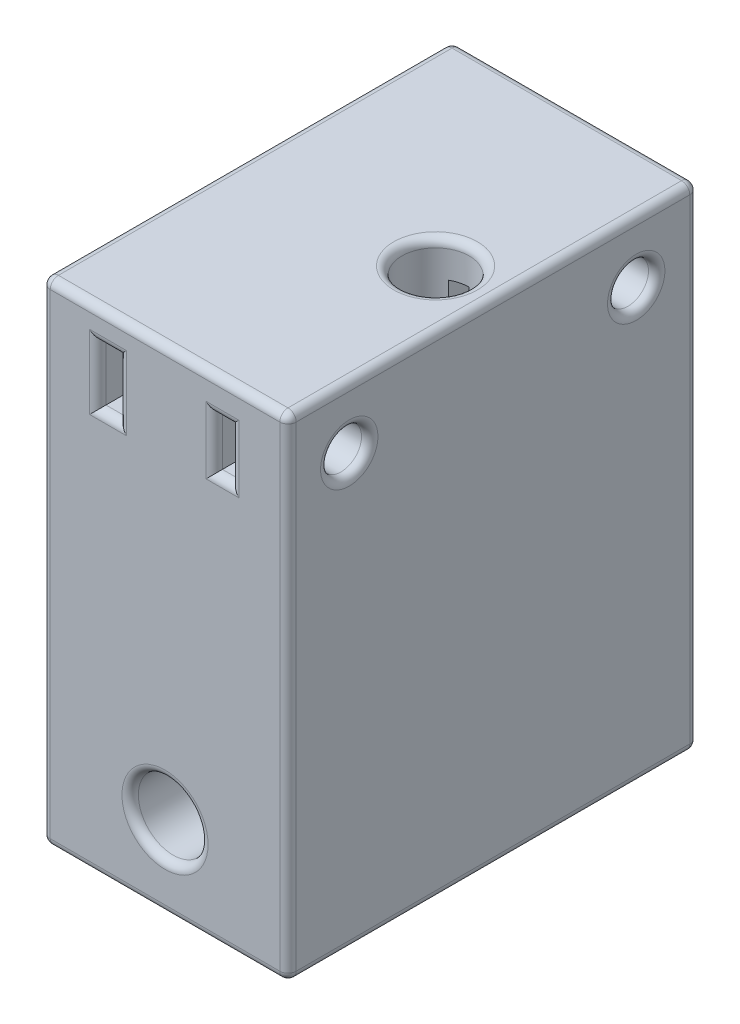
from build123d import *

# Parameters (mm, degrees)
SKETCH_1_W          = 30
SKETCH_1_H          = 60
SKETCH_1_R          = 4.25
EXTRUDE_1_DEPTH     = 50
SKETCH_2_W          = 2.5
SKETCH_2_H          = 7
SKETCH_2_W_2        = 2
SKETCH_2_H_2        = 6.2
CUT_EXTRUDE_1_DEPTH = 50
SKETCH_4_R          = 2.5
CUT_EXTRUDE_2_DEPTH = 7
FILLET_1_R          = 1
FILLET_2_R          = 1
FILLET_3_R          = 1
FILLET_4_R          = 1
FILLET_5_R          = 1
FILLET_6_R          = 1
SKETCH_5_R          = 4.1
CUT_EXTRUDE_3_DEPTH = 21
FILLET_7_R          = 1
FILLET_8_R          = 1


with BuildPart() as part:
    # 草图1 → 凸台-拉伸1 (new body)
    with BuildSketch(Plane.XY):
        with Locations((6.369509044, 21.447028424)):
            Rectangle(SKETCH_1_W, SKETCH_1_H)
        with Locations((6.369509044, 1.447028424)):
            Circle(SKETCH_1_R, mode=Mode.SUBTRACT)
    extrude(amount=EXTRUDE_1_DEPTH)

    # 草图2 → 切除-拉伸1 (cut)
    with BuildSketch(Plane.XY.offset(50)):
        with Locations((-0.580490956, 44.147028424)):
            Rectangle(SKETCH_2_W, SKETCH_2_H)
        with Locations((13.369509044, 44.047028424)):
            Rectangle(SKETCH_2_W_2, SKETCH_2_H_2)
    extrude(amount=-CUT_EXTRUDE_1_DEPTH, mode=Mode.SUBTRACT)

    # 草图4 → 切除-拉伸2 (cut)
    with BuildSketch(Plane(origin=(21.369509044, 0, 0), x_dir=(0, 0, -1), z_dir=(1, 0, 0))):
        with Locations((-42.532463012, 43.947028424)):
            Circle(SKETCH_4_R)
        with Locations((-7.532463012, 43.947028424)):
            Circle(SKETCH_4_R)
    extrude(amount=-CUT_EXTRUDE_2_DEPTH, mode=Mode.SUBTRACT)

    # 圆角1
    fillet_1_edges = [part.edges().sort_by_distance(p)[0] for p in [
        (12.369509044, 44.047028424, 50),
        (13.369509044, 40.947028424, 50),
        (14.369509044, 44.047028424, 50),
        (13.369509044, 47.147028424, 50),
    ]]
    fillet(fillet_1_edges, radius=FILLET_1_R)

    # 圆角2
    fillet_2_edges = [part.edges().sort_by_distance(p)[0] for p in [
        (-1.830490956, 44.147028424, 50),
        (-0.580490956, 40.647028424, 50),
        (0.669509044, 44.147028424, 50),
        (-0.580490956, 47.647028424, 50),
    ]]
    fillet(fillet_2_edges, radius=FILLET_2_R)

    # 圆角3
    fillet_3_edges = [part.edges().sort_by_distance(p)[0] for p in [
        (2.119509044, 1.447028424, 50),
    ]]
    fillet(fillet_3_edges, radius=FILLET_3_R)

    # 圆角4
    fillet_4_edges = [part.edges().sort_by_distance(p)[0] for p in [
        (21.369509044, 43.947028424, 45.032463012),
    ]]
    fillet(fillet_4_edges, radius=FILLET_4_R)

    # 圆角5
    fillet_5_edges = [part.edges().sort_by_distance(p)[0] for p in [
        (21.369509044, 43.947028424, 10.032463012),
    ]]
    fillet(fillet_5_edges, radius=FILLET_5_R)

    # 圆角6
    fillet_6_edges = [part.edges().sort_by_distance(p)[0] for p in [
        (2.119509044, 1.447028424, 0),
        (-1.830490956, 44.147028424, 0),
        (-0.580490956, 47.647028424, 0),
        (0.669509044, 44.147028424, 0),
        (-0.580490956, 40.647028424, 0),
        (12.369509044, 44.047028424, 0),
        (13.369509044, 47.147028424, 0),
        (14.369509044, 44.047028424, 0),
        (13.369509044, 40.947028424, 0),
    ]]
    fillet(fillet_6_edges, radius=FILLET_6_R)

    # 草图5 → 切除-拉伸3 (cut)
    with BuildSketch(Plane(origin=(0, 51.447028424, 0), x_dir=(1, 0, 0), z_dir=(0, 1, 0))):
        with Locations((14.369509044, -25)):
            Circle(SKETCH_5_R)
    extrude(amount=-CUT_EXTRUDE_3_DEPTH, mode=Mode.SUBTRACT)

    # 圆角7
    fillet_7_edges = [part.edges().sort_by_distance(p)[0] for p in [
        (10.269509044, 51.447028424, 25),
    ]]
    fillet(fillet_7_edges, radius=FILLET_7_R)

    # 圆角8
    fillet_8_edges = [part.edges().sort_by_distance(p)[0] for p in [
        (21.369509044, 21.447028424, 50),
        (6.369509044, 51.447028424, 50),
        (-8.630490956, 21.447028424, 50),
        (6.369509044, 51.447028424, 0),
        (21.369509044, 21.447028424, 0),
        (6.369509044, -8.552971576, 0),
        (-8.630490956, 21.447028424, 0),
        (6.369509044, -8.552971576, 50),
        (-8.630490956, 51.447028424, 25),
        (21.369509044, 51.447028424, 25),
        (21.369509044, -8.552971576, 25),
        (-8.630490956, -8.552971576, 25),
    ]]
    fillet(fillet_8_edges, radius=FILLET_8_R)


solid = part.part
